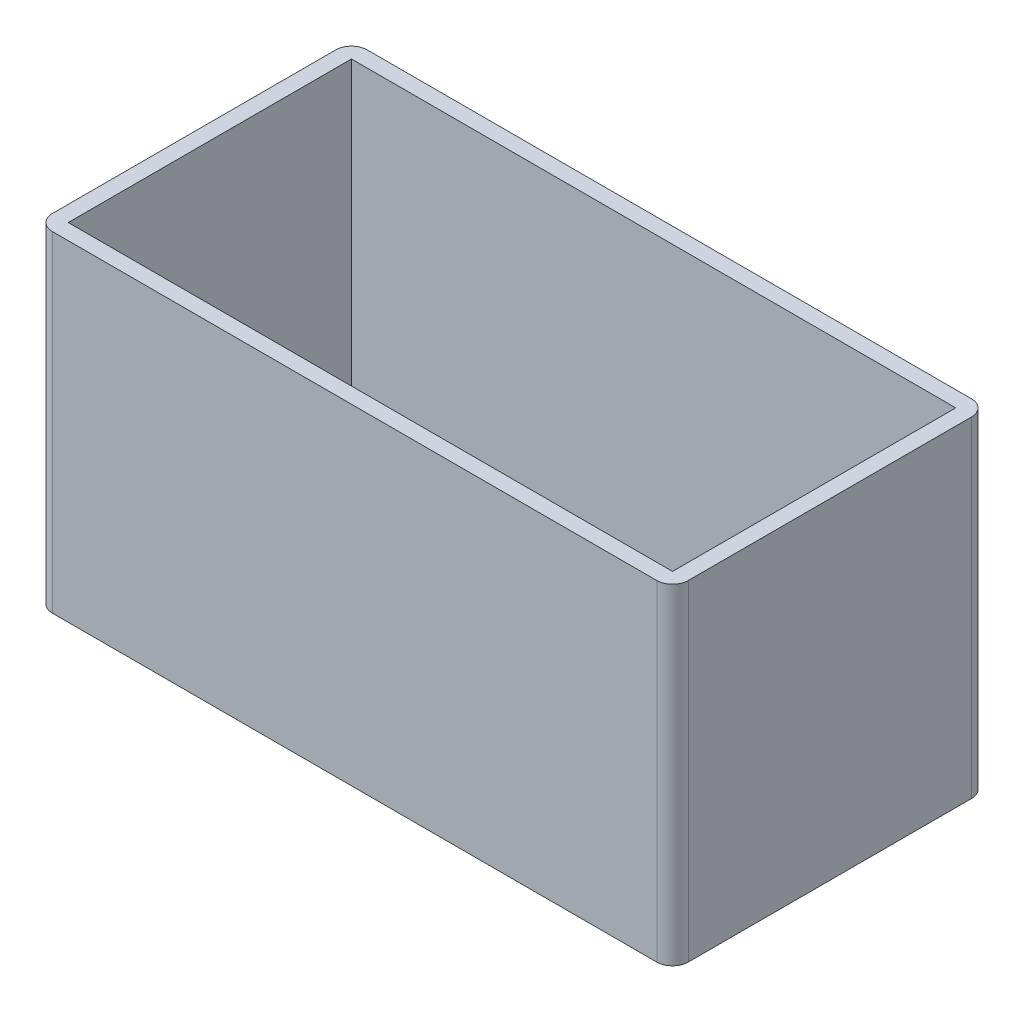
from build123d import *

# Parameters (mm, degrees)
ESQUISSE1_W        = 40.4
ESQUISSE1_H        = 20
ESQUISSE1_W_2      = 38.4
ESQUISSE1_H_2      = 18
BOSS_EXTRU_1_DEPTH = 21
CONG_1_R           = 1


with BuildPart() as part:
    # Esquisse1 → Boss.-Extru.1 (new body)
    with BuildSketch(Plane(origin=(0, 0, 0), x_dir=(1, 0, 0), z_dir=(0, 1, 0))):
        with Locations((-8.710891089, 0)):
            Rectangle(ESQUISSE1_W, ESQUISSE1_H)
        with Locations((-8.710891089, 0)):
            Rectangle(ESQUISSE1_W_2, ESQUISSE1_H_2, mode=Mode.SUBTRACT)
    extrude(amount=BOSS_EXTRU_1_DEPTH)

    # Congé1
    cong_1_edges = [part.edges().sort_by_distance(p)[0] for p in [
        (-28.910891089, 10.5, -10),
        (11.489108911, 10.5, -10),
        (11.489108911, 10.5, 10),
        (-28.910891089, 10.5, 10),
    ]]
    fillet(cong_1_edges, radius=CONG_1_R)


solid = part.part
